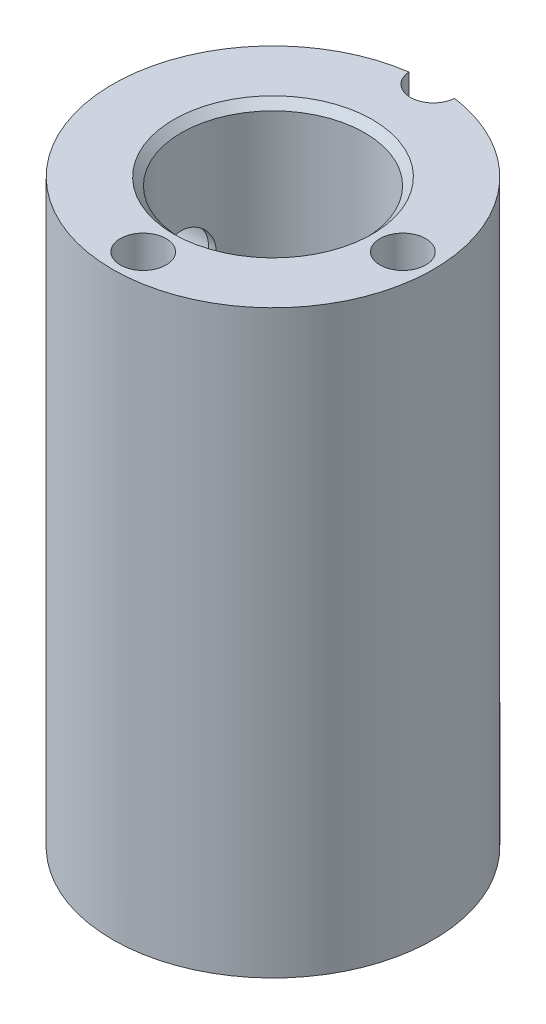
from build123d import *

# Parameters (mm, degrees)
SKETCH1_R                       = 10.5
BOSS_EXTRUDE1_DEPTH             = 38
SKETCH2_R                       = 6
CUT_EXTRUDE1_DEPTH              = 41.798284278
F_3_9_3_9_DIAMETER_HOLE1_REACH  = 46.668
F_3_9_3_9_DIAMETER_HOLE1_BORE_R = 1.95
F_3_0MM_DOWEL_HOLE1_D           = 3
F_3_0MM_DOWEL_HOLE1_DEPTH       = 6
F_3_0MM_DOWEL_HOLE1_TIP         = 0.901290929
CHAMFER1_SIZE                   = 0.5
F_3_0MM_DOWEL_HOLE2_D           = 3
F_3_0MM_DOWEL_HOLE2_DEPTH       = 8
F_3_0MM_DOWEL_HOLE2_TIP         = 0.901290929


with BuildPart() as part:
    # Sketch1 → Boss-Extrude1 (new body)
    with BuildSketch(Plane(origin=(0, 0, 0), x_dir=(1, 0, 0), z_dir=(0, 1, 0))):
        with Locations(Location((0, 0, 0), (0, 0, 270))):
            Circle(SKETCH1_R)
    extrude(amount=BOSS_EXTRUDE1_DEPTH)

    # Sketch2 → Cut-Extrude1 (cut, through all)
    with BuildSketch(Plane(origin=(0, 38, 0), x_dir=(1, 0, 0), z_dir=(0, 1, 0))):
        with Locations(Location((0, 0, 0), (0, 0, 270))):
            Circle(SKETCH2_R)
    extrude(amount=-CUT_EXTRUDE1_DEPTH, mode=Mode.SUBTRACT)

    # Ø3.9 (3.9) Diameter Hole1 bore → Ø3.9 (3.9) Diameter Hole1 (cut, up to next)
    with BuildSketch(Plane.ZY.offset(10.5), mode=Mode.PRIVATE) as f_3_9_3_9_diameter_hole1_sk1:
        with Locations((0, 30)):
            Circle(F_3_9_3_9_DIAMETER_HOLE1_BORE_R)
    f_3_9_3_9_diameter_hole1_tool1 = extrude(f_3_9_3_9_diameter_hole1_sk1.sketch, amount=-F_3_9_3_9_DIAMETER_HOLE1_REACH, mode=Mode.PRIVATE) & part.part
    f_3_9_3_9_diameter_hole1 = f_3_9_3_9_diameter_hole1_tool1.solids().sort_by_distance((-10.5, 30, 0))[0]
    add(f_3_9_3_9_diameter_hole1, mode=Mode.SUBTRACT)

    # Sketch9 → Ø5.0mm Dowel Hole1 (revolve, cut)
    with BuildSketch(Plane(origin=(-10.5, 30, 0), x_dir=(0, 0, 1), z_dir=(0, 1, 0))):
        Polygon((0, 0), (0, 5.502151548), (2.5, 4), (2.5, 0), align=None)
    f_5_0mm_dowel_hole1 = revolve(axis=Axis((-16.85, 30, 0), (1, 0, 0)), mode=Mode.SUBTRACT)

    # Mirror1: Ø3.9 (3.9) Diameter Hole1, Ø5.0mm Dowel Hole1 across plane
    add(f_3_9_3_9_diameter_hole1.mirror(Plane(origin=(0, 18.5, 0), x_dir=(0, 0, 1), z_dir=(0, -1, 0))), mode=Mode.SUBTRACT)
    add(f_5_0mm_dowel_hole1.mirror(Plane(origin=(0, 18.5, 0), x_dir=(0, 0, 1), z_dir=(0, -1, 0))), mode=Mode.SUBTRACT)

    # Ø3.0mm Dowel Hole1
    with Locations(Plane(origin=(0, 38, 0), x_dir=(1, 0, 0), z_dir=(0, 1, 0))):
        with Locations((8.5, 0), (0, -8.5)):
            Hole(F_3_0MM_DOWEL_HOLE1_D / 2, depth=F_3_0MM_DOWEL_HOLE1_DEPTH)
            with Locations((0, 0, -(F_3_0MM_DOWEL_HOLE1_DEPTH + F_3_0MM_DOWEL_HOLE1_TIP / 2))):  # 118° drill point
                Cone(0, F_3_0MM_DOWEL_HOLE1_D / 2, F_3_0MM_DOWEL_HOLE1_TIP, mode=Mode.SUBTRACT)

    # Chamfer1
    chamfer1_edges = [part.edges().sort_by_distance(p)[0] for p in [
        (0, 38, -6),
    ]]
    chamfer(chamfer1_edges, length=CHAMFER1_SIZE)

    # Ø3.0mm Dowel Hole2
    with Locations(Plane(origin=(0, 38, 0), x_dir=(1, 0, 0), z_dir=(0, 1, 0))):
        with Locations((0, 10.5)):
            Hole(F_3_0MM_DOWEL_HOLE2_D / 2, depth=F_3_0MM_DOWEL_HOLE2_DEPTH)
            with Locations((0, 0, -(F_3_0MM_DOWEL_HOLE2_DEPTH + F_3_0MM_DOWEL_HOLE2_TIP / 2))):  # 118° drill point
                Cone(0, F_3_0MM_DOWEL_HOLE2_D / 2, F_3_0MM_DOWEL_HOLE2_TIP, mode=Mode.SUBTRACT)


solid = part.part
